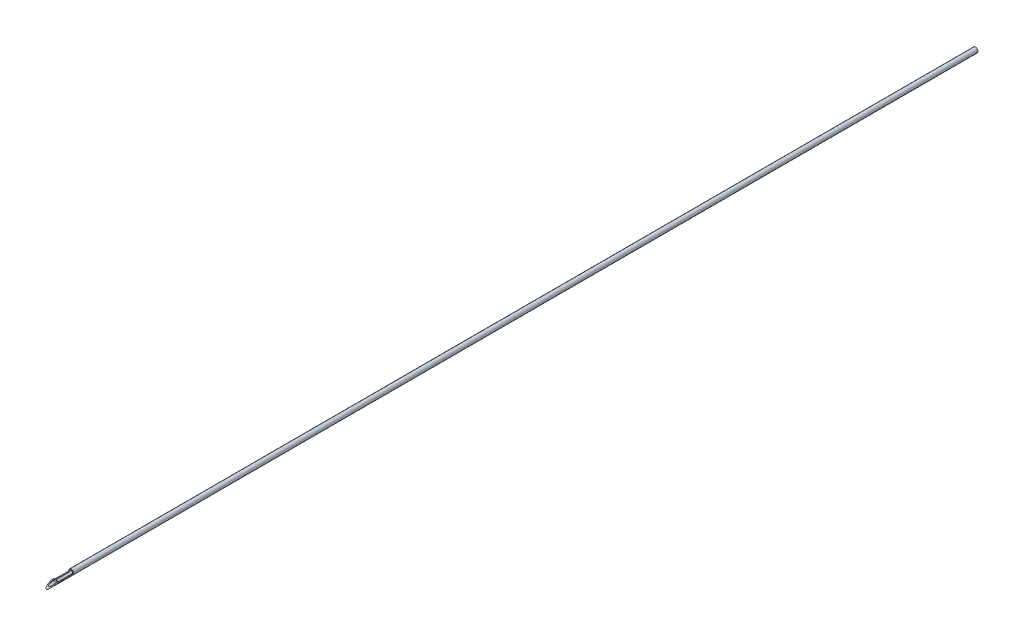
from build123d import *

# Parameters (mm, degrees)
SKETCH1_R           = 0.405
SKETCH1_R_2         = 0.255
BOSS_EXTRUDE1_DEPTH = 150
CUT_EXTRUDE1_DEPTH  = 0.5


with BuildPart() as part:
    # Sketch1 → Boss-Extrude1 (new body)
    with BuildSketch(Plane.XY):
        Circle(SKETCH1_R)
        Circle(SKETCH1_R_2, mode=Mode.SUBTRACT)
    extrude(amount=BOSS_EXTRUDE1_DEPTH)

    # Sketch2 → Cut-Extrude1 (cut, symmetric)
    with BuildSketch(Plane(origin=(0, 0, 0), x_dir=(0, 0, -1), z_dir=(1, 0, 0))):
        Polygon((-150, -0.405), (-148.514947888, 0.195), (-148.514947888, -0.055), (-146.014947888, -0.055), (-146.014947888, 0.595), (-150.3, 0.595), (-150.3, -0.405), align=None)
    extrude(amount=CUT_EXTRUDE1_DEPTH, both=True, mode=Mode.SUBTRACT)


solid = part.part
